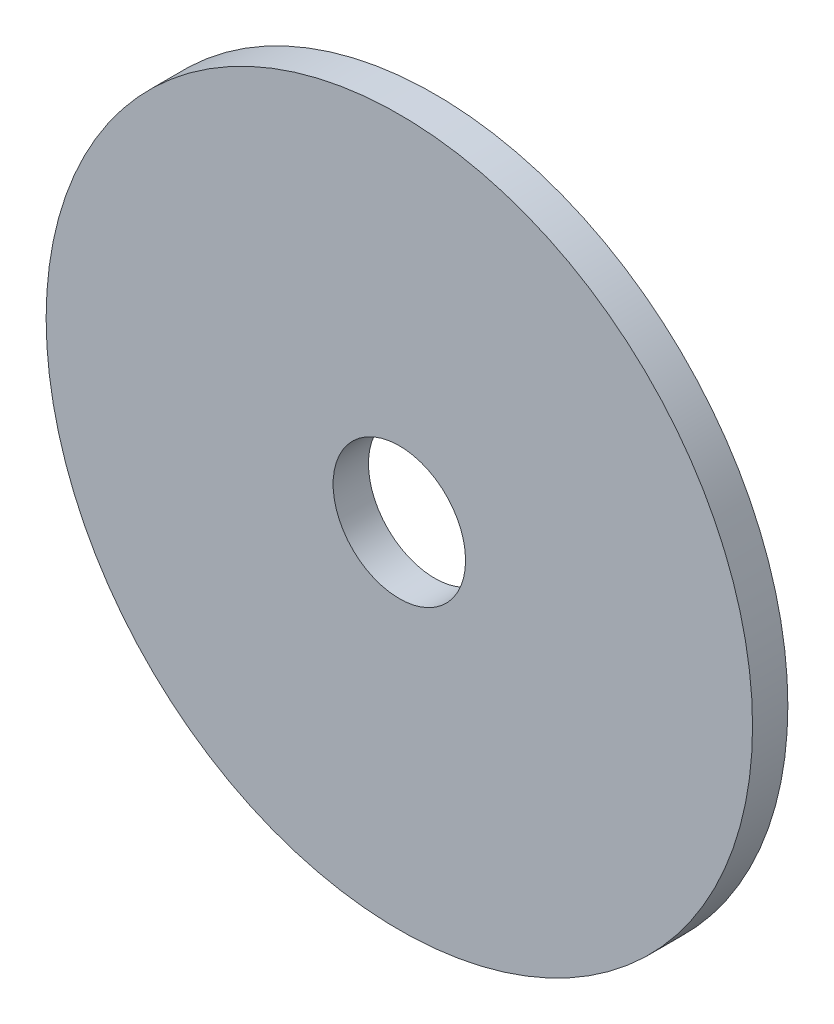
from build123d import *

# Parameters (mm, degrees)
SKETCH1_R           = 12.7
SKETCH1_R_2         = 2.38125
BOSS_EXTRUDE1_DEPTH = 1.27


with BuildPart() as part:
    # Sketch1 → Boss-Extrude1 (new body)
    with BuildSketch(Plane.XY):
        Circle(SKETCH1_R)
        Circle(SKETCH1_R_2, mode=Mode.SUBTRACT)
    extrude(amount=BOSS_EXTRUDE1_DEPTH)


solid = part.part
